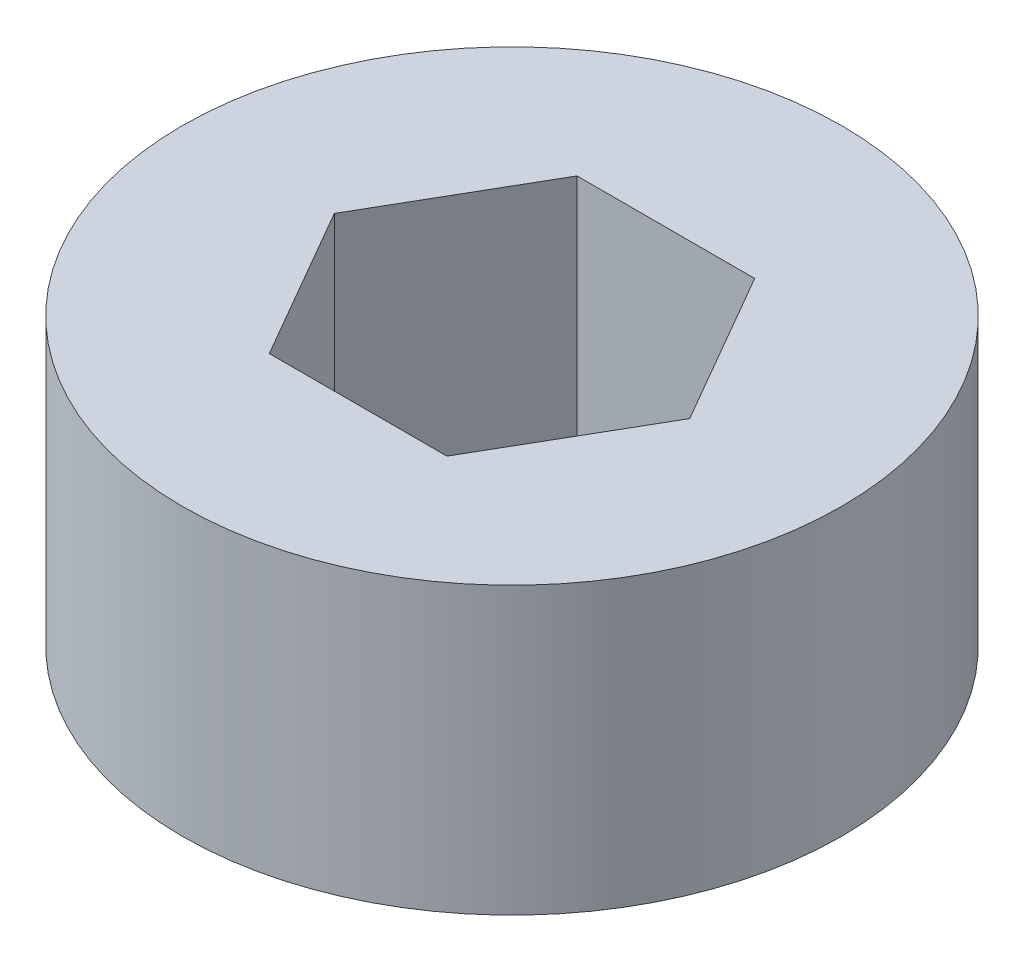
from build123d import *

# Parameters (mm, degrees)
SKETCH1_R               = 15
BOSS_EXTRUDE1_DEPTH     = 13
CUT_EXTRUDE1_DEPTH      = 26
CUT_EXTRUDE1_DEPTH_BACK = 32


with BuildPart() as part:
    # Sketch1 → Boss-Extrude1 (new body)
    with BuildSketch(Plane(origin=(0, 0, 0), x_dir=(1, 0, 0), z_dir=(0, 1, 0))):
        Circle(SKETCH1_R)
    extrude(amount=BOSS_EXTRUDE1_DEPTH)

    # Sketch3 → Cut-Extrude1 (cut, two sides)
    with BuildSketch(Plane(origin=(0, 13, 0), x_dir=(1, 0, 0), z_dir=(0, 1, 0))) as cut_extrude1_sk:
        Polygon((8.082903769, 0), (4.041451884, 7), (-4.041451884, 7), (-8.082903769, 0), (-4.041451884, -7), (4.041451884, -7), align=None)
    extrude(amount=CUT_EXTRUDE1_DEPTH, mode=Mode.SUBTRACT)
    extrude(cut_extrude1_sk.sketch, amount=-CUT_EXTRUDE1_DEPTH_BACK, mode=Mode.SUBTRACT)


solid = part.part
